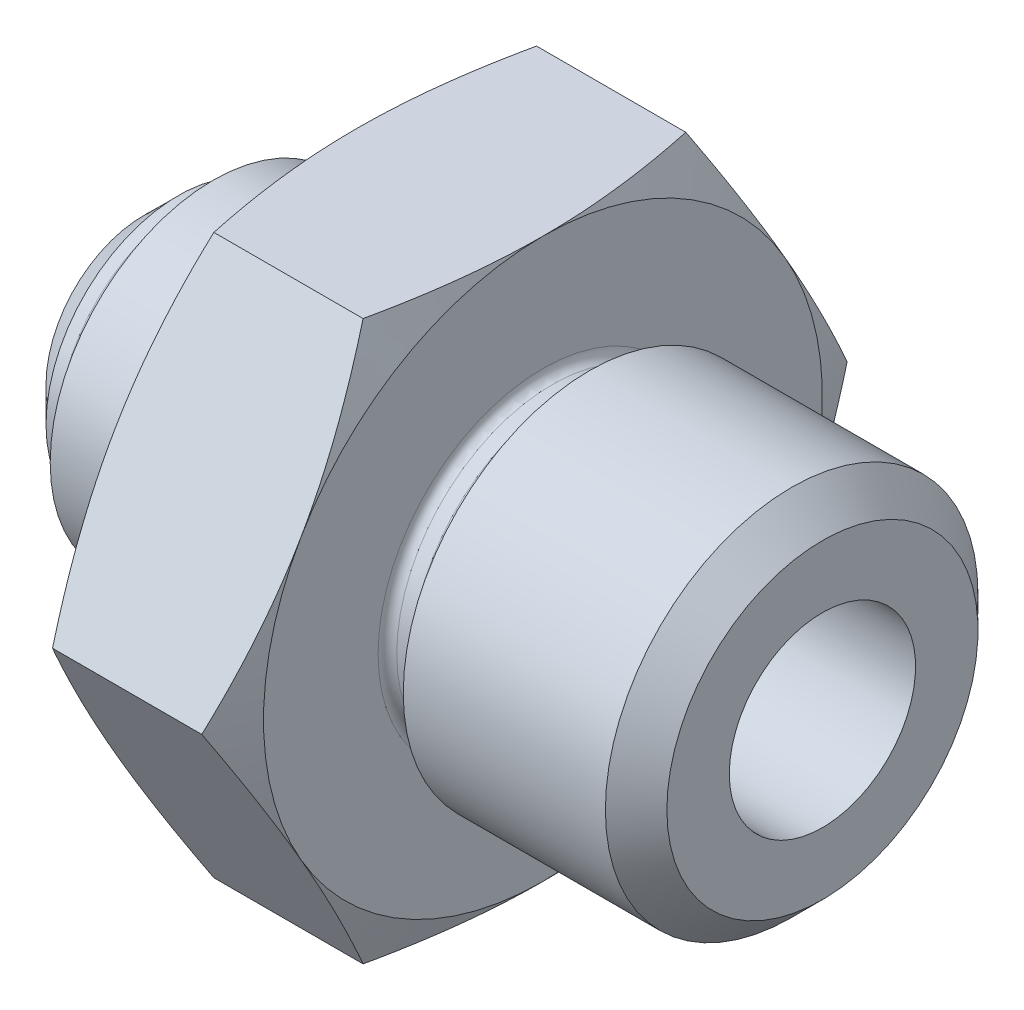
from build123d import *
from build123d.topology import SkipClean

# Parameters (mm, degrees)
CUT_EXTRUDE1_REACH = 41.638
SKETCH2_W          = 44.696360066
SKETCH2_H          = 10.879518223
CIRPATTERN1_COUNT  = 6
FILLET1_R          = 0.4


with BuildPart() as part:
    # Sketch1 → Revolve1 (revolve)
    with BuildSketch(Plane.XY, mode=Mode.PRIVATE) as revolve1_sk:
        Polygon((0, 4), (29.14, 4), (29.14, 6.68), (27.82, 8), (19.14, 8), (18.377897645, 6.68), (17.14, 6.68), (17.14, 12), (14.14, 19), (12.14, 19), (9.14, 12), (9.14, 5.68), (7.902102355, 5.68), (7.14, 7), (2.98, 7), (2.217897645, 5.68), (1.48, 5.68), (0, 4.2), align=None)
    revolve(revolve1_sk.sketch.rotate(Axis((0, 0, 0), (1, 0, 0)), 90), axis=Axis((0, 0, 0), (1, 0, 0)))

    # Sketch2 → Cut-Extrude1 (cut, up to next)
    with BuildSketch(Plane(origin=(0, 0, 0), x_dir=(0, 0, -1), z_dir=(1, 0, 0)), mode=Mode.PRIVATE) as cut_extrude1_sk1:
        with Locations((0.211971912, 17.439759112)):
            Rectangle(SKETCH2_W, SKETCH2_H)
    cut_extrude1_tool1 = extrude(cut_extrude1_sk1.sketch, amount=CUT_EXTRUDE1_REACH, mode=Mode.PRIVATE) & part.part
    cut_extrude1 = cut_extrude1_tool1.solids().sort_by_distance((0, 17.439759, -0.211972))[0]
    add(cut_extrude1, mode=Mode.SUBTRACT)

    # CirPattern1: Cut-Extrude1 ×6 about axis
    cirpattern1_axis = Axis((0, 0, 0), (1, 0, 0))
    for i in range(1, CIRPATTERN1_COUNT):
        add(cut_extrude1.rotate(cirpattern1_axis, i * 360 / CIRPATTERN1_COUNT), mode=Mode.SUBTRACT)

    # Fillet1
    fillet1_edges = [part.edges().sort_by_distance(p)[0] for p in [
        (18.377897645, 0, -6.68),
        (17.14, 0, -6.68),
        (9.14, 0, -5.68),
        (7.902102355, 0, -5.68),
        (2.217897645, 0, -5.68),
    ]]
    fillet(fillet1_edges, radius=FILLET1_R)


solid = part.part
